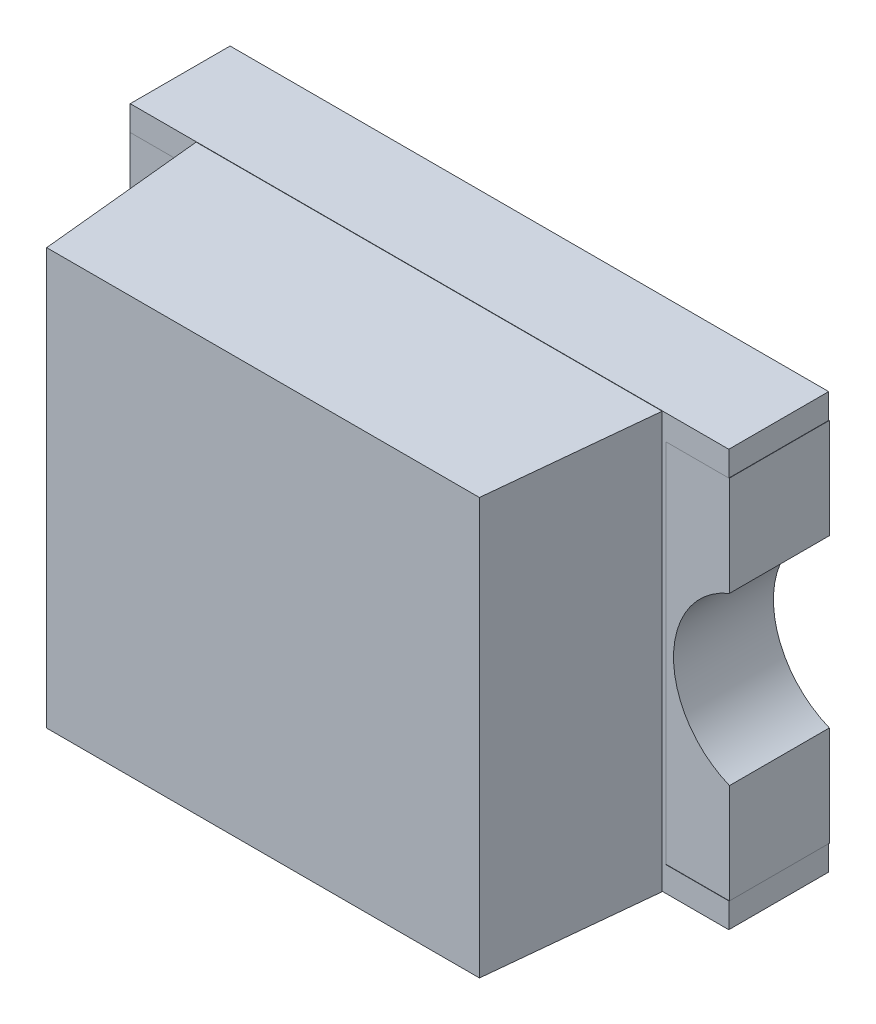
from build123d import *

# Parameters (mm, degrees)
EXTRUDE1_DEPTH   = 0.3
EXTRUDE1_2_DEPTH = 0.3
EXTRUDE2_START   = 0.001
EXTRUDE2_DEPTH   = 0.3
EXTRUDE3_DEPTH   = 1.25
SKETCH4_W        = 0.2
SKETCH4_H        = 0.2
EXTRUDE4_DEPTH   = 0.2
EXTRUDE5_START   = 0.0001
SKETCH5_W        = 0.1999
SKETCH5_H        = 0.1999
EXTRUDE5_DEPTH   = 0.199
SKETCH6_W        = 0.21
SKETCH6_H        = 1.1
EXTRUDE6_DEPTH   = 0.001


with BuildPart() as part:
    # Sketch1 → Extrude1 (new body)
    with BuildSketch(Plane.XY):
        with BuildLine():
            Line((0, 0), (-0.4, 0))
            Line((-0.4, 0), (-0.4, 0.3))
            ThreePointArc((-0.4, 0.3), (-0.23198039, 0.55), (-0.4, 0.8))
            Line((-0.4, 0.8), (-0.4, 1.1))
            Line((-0.4, 1.1), (0, 1.1))
            Line((0, 1.1), (0, 0))
        make_face()
    extrude(amount=EXTRUDE1_DEPTH)



with BuildPart() as body_2:
    # Sketch1 → Extrude1 2 (new body)
    with BuildSketch(Plane.XY):
        with BuildLine():
            Line((1, 0), (1.4, 0))
            Line((1.4, 0), (1.4, 0.3))
            ThreePointArc((1.4, 0.3), (1.23198039, 0.55), (1.4, 0.8))
            Line((1.4, 0.8), (1.4, 1.1))
            Line((1.4, 1.1), (1, 1.1))
            Line((1, 1.1), (1, 0))
        make_face()
    extrude(amount=EXTRUDE1_2_DEPTH)


with BuildPart() as body_3:
    # Sketch2 → Extrude2 (new body)
    with BuildSketch(Plane.XY.offset(0.3).offset(EXTRUDE2_START)):
        Polygon((-0.399, 1.1), (-0.399, 1.175), (1.399, 1.175), (1.399, 1.1), (1, 1.1), (1, 0), (1.399, 0), (1.399, -0.075), (-0.399, -0.075), (-0.399, 0), (0, 0), (0, 1.1), align=None)
    extrude(amount=-EXTRUDE2_DEPTH)


with BuildPart() as body_4:
    # Sketch3 → Extrude3 (new body)
    with BuildSketch(Plane.XZ.offset(0.075)):
        Polygon((-0.2, 0.302), (1.2, 0.302), (1.15, 0.801), (-0.15, 0.801), align=None)
    extrude(amount=-EXTRUDE3_DEPTH)

    # Sketch4 → Extrude4 (cut)
    with BuildSketch(Plane.XY.offset(0.301)):
        with Locations((0.85, 0.55)):
            Rectangle(SKETCH4_W, SKETCH4_H)
    extrude(amount=EXTRUDE4_DEPTH, mode=Mode.SUBTRACT)


with BuildPart() as body_5:
    # Sketch5 → Extrude5 (new body)
    with BuildSketch(Plane.XY.offset(0.301).offset(EXTRUDE5_START)):
        with Locations((0.85, 0.55)):
            Rectangle(SKETCH5_W, SKETCH5_H)
    extrude(amount=EXTRUDE5_DEPTH)


with BuildPart() as part_1:
    add(part.part)

    add(body_2.part)  # Extrude6 merges body 2

    add(body_3.part)  # Extrude6 merges body 3
    # Sketch6 → Extrude6 (add)
    with BuildSketch(Plane.XY.offset(0.3)):
        with Locations((1.105, 0.55)):
            Rectangle(SKETCH6_W, SKETCH6_H)
        with Locations((-0.105, 0.55)):
            Rectangle(SKETCH6_W, SKETCH6_H)
    extrude(amount=EXTRUDE6_DEPTH)


solid = Compound([body_4.part, body_5.part, part_1.part])
